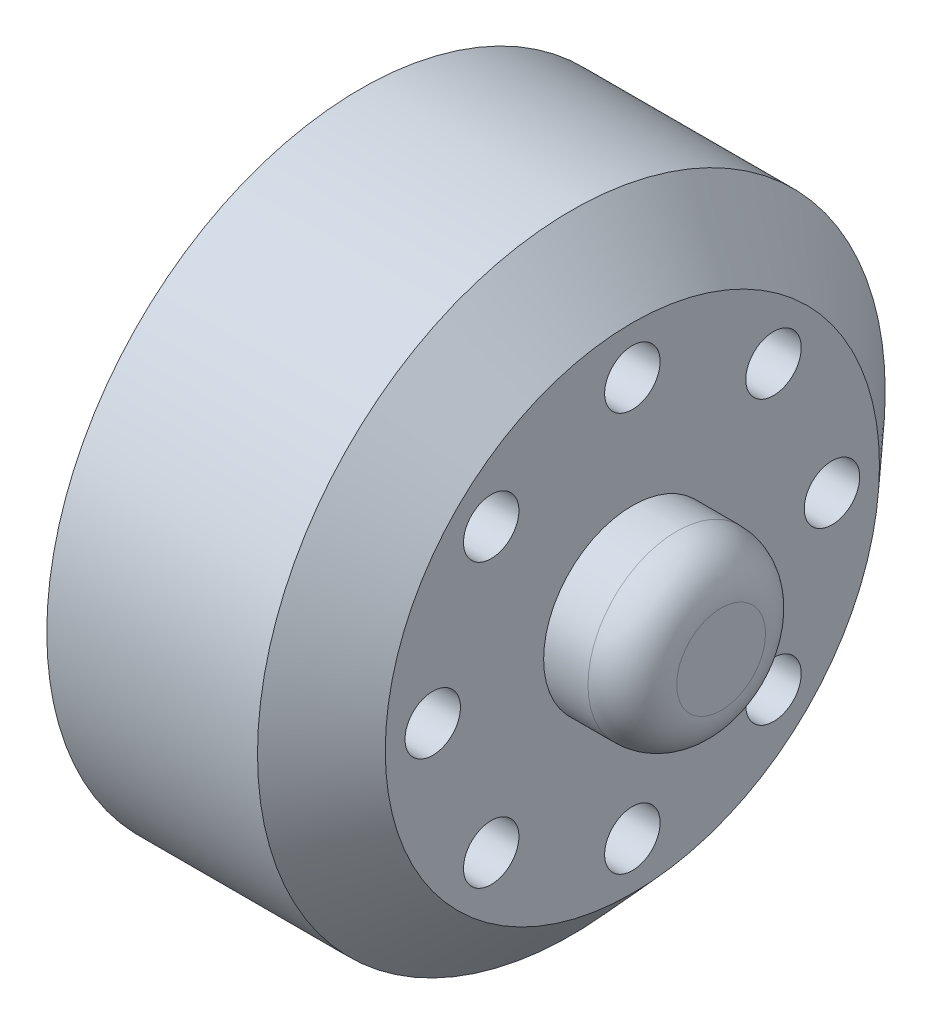
from build123d import *

# Parameters (mm, degrees)
FILLET1_R          = 2
SKETCH2_R          = 1.25
CUT_EXTRUDE1_DEPTH = 12.25
SKETCH3_R          = 2.5
CUT_EXTRUDE2_DEPTH = 7.25


with BuildPart() as part:
    # Sketch1 → Revolve1 (revolve)
    with BuildSketch(Plane(origin=(0, 0, 0), x_dir=(1, 0, 0), z_dir=(0, 1, 0))):
        Polygon((-1.630434783, 14.15), (7.869565217, 14.15), (10.619565217, 11.140476118), (10.619565217, 4), (14.619565217, 4), (14.619565217, 0), (13.372742768, 0), (5.369565217, 0), (5.369565217, 10.5), (-1.630434783, 10.5), align=None)
    revolve(axis=Axis((-12.391304348, 0, 0), (1, 0, 0)))

    # Fillet1
    fillet1_edges = [part.edges().sort_by_distance(p)[0] for p in [
        (14.619565217, 0, 4),
    ]]
    fillet(fillet1_edges, radius=FILLET1_R)

    # Sketch2 → Cut-Extrude1 (cut)
    with BuildSketch(Plane(origin=(10.619565217, 0, 0), x_dir=(0, 0, -1), z_dir=(1, 0, 0))):
        with Locations((0, 9)):
            Circle(SKETCH2_R)
        with Locations((6.363961031, 6.363961031)):
            Circle(SKETCH2_R)
        with Locations((9, 0)):
            Circle(SKETCH2_R)
        with Locations((6.363961031, -6.363961031)):
            Circle(SKETCH2_R)
        with Locations((0, -9)):
            Circle(SKETCH2_R)
        with Locations((-6.363961031, -6.363961031)):
            Circle(SKETCH2_R)
        with Locations((-9, 0)):
            Circle(SKETCH2_R)
        with Locations((-6.363961031, 6.363961031)):
            Circle(SKETCH2_R)
    extrude(amount=-CUT_EXTRUDE1_DEPTH, mode=Mode.SUBTRACT)

    # Sketch3 → Cut-Extrude2 (cut)
    with BuildSketch(Plane.ZY.offset(1.630434783)):
        with Locations((0, 9)):
            Circle(SKETCH3_R)
        with Locations((6.363961031, 6.363961031)):
            Circle(SKETCH3_R)
        with Locations((9, 0)):
            Circle(SKETCH3_R)
        with Locations((6.363961031, -6.363961031)):
            Circle(SKETCH3_R)
        with Locations((0, -9)):
            Circle(SKETCH3_R)
        with Locations((-6.363961031, -6.363961031)):
            Circle(SKETCH3_R)
        with Locations((-9, 0)):
            Circle(SKETCH3_R)
        with Locations((-6.363961031, 6.363961031)):
            Circle(SKETCH3_R)
    extrude(amount=-CUT_EXTRUDE2_DEPTH, mode=Mode.SUBTRACT)


solid = part.part
